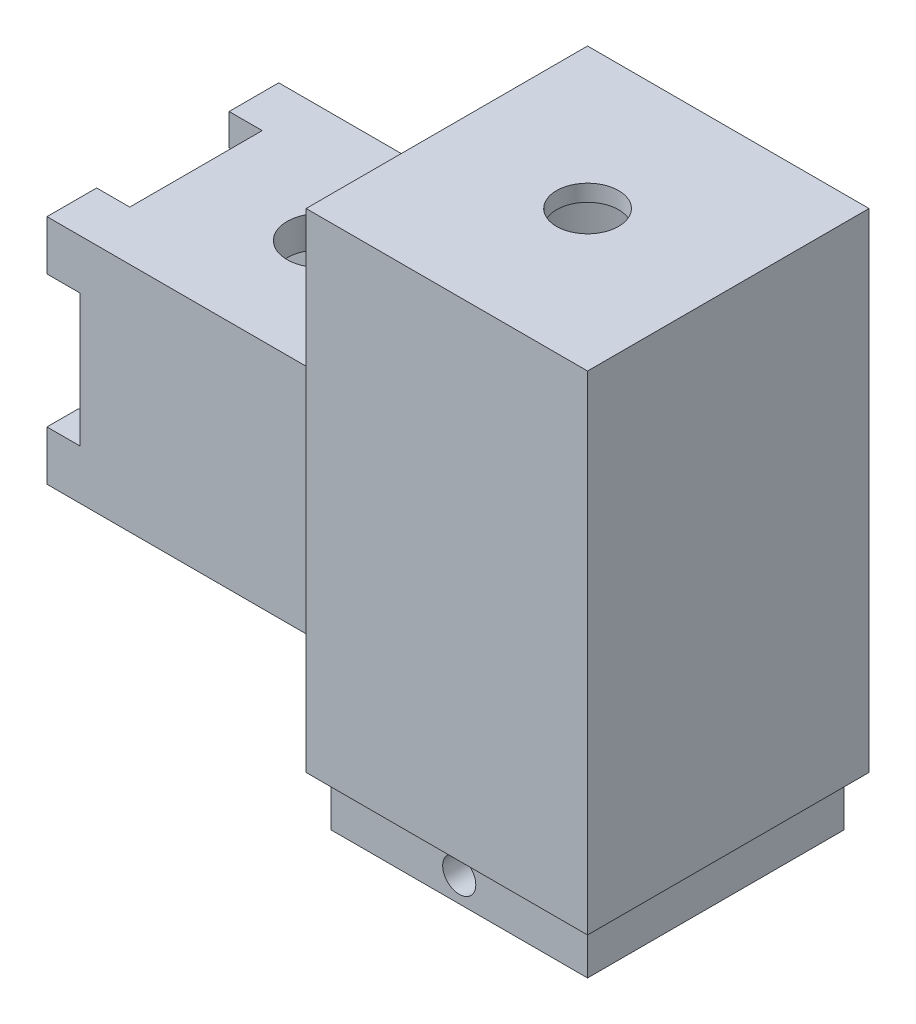
from build123d import *

# Parameters (mm, degrees)
CROQUIS1_W              = 28
CROQUIS1_H              = 28
CROQUIS1_W_2            = 20.4
CROQUIS1_H_2            = 20.4
SALIENTE_EXTRUIR1_DEPTH = 30.3
CROQUIS2_W              = 34
CROQUIS2_H              = 34
SALIENTE_EXTRUIR2_DEPTH = 31.5
CROQUIS3_R              = 12.625
CORTAR_EXTRUIR1_DEPTH   = 63
CROQUIS4_W              = 34
CROQUIS4_H              = 34
SALIENTE_EXTRUIR3_DEPTH = 2
CORTAR_EXTRUIR2_REACH   = 67
CROQUIS5_R              = 3.75
CORTAR_EXTRUIR3_REACH   = 36
CROQUIS6_W              = 15
CROQUIS6_H              = 11
CROQUIS7_W              = 34
CROQUIS7_H              = 34
CROQUIS7_W_2            = 31
CROQUIS7_H_2            = 31
CORTAR_EXTRUIR4_DEPTH   = 6
CROQUIS8_R              = 2
CORTAR_EXTRUIR7_DEPTH   = 40
CROQUIS10_R             = 4
CORTAR_EXTRUIR8_DEPTH   = 25.5
SALIENTE_EXTRUIR4_DEPTH = 4


with BuildPart() as part:
    # Croquis1 → Saliente-Extruir1 (new body)
    with BuildSketch(Plane(origin=(0, 0, 0), x_dir=(0, 0, -1), z_dir=(1, 0, 0))):
        Rectangle(CROQUIS1_W, CROQUIS1_H)
        Rectangle(CROQUIS1_W_2, CROQUIS1_H_2, mode=Mode.SUBTRACT)
    extrude(amount=SALIENTE_EXTRUIR1_DEPTH)

    # Croquis2 → Saliente-Extruir2 (add, symmetric)
    with BuildSketch(Plane(origin=(0, 0, 0), x_dir=(1, 0, 0), z_dir=(0, 1, 0))):
        with Locations((47.3, 0)):
            Rectangle(CROQUIS2_W, CROQUIS2_H)
    extrude(amount=SALIENTE_EXTRUIR2_DEPTH, both=True)

    # Croquis3 → Cortar-Extruir1 (cut)
    with BuildSketch(Plane.XZ.offset(31.5)):
        with Locations((47.3, 0)):
            Circle(CROQUIS3_R)
    extrude(amount=-CORTAR_EXTRUIR1_DEPTH, mode=Mode.SUBTRACT)

    # Croquis4 → Saliente-Extruir3 (add)
    with BuildSketch(Plane(origin=(0, 31.5, 0), x_dir=(1, 0, 0), z_dir=(0, 1, 0))):
        with Locations((47.3, 0)):
            Rectangle(CROQUIS4_W, CROQUIS4_H)
    extrude(amount=SALIENTE_EXTRUIR3_DEPTH)

    # Croquis5 → Cortar-Extruir2 (cut, up to next)
    with BuildSketch(Plane(origin=(0, 33.5, 0), x_dir=(1, 0, 0), z_dir=(0, 1, 0)), mode=Mode.PRIVATE) as cortar_extruir2_sk1:
        with Locations((47.3, 0)):
            Circle(CROQUIS5_R)
    cortar_extruir2_tool1 = extrude(cortar_extruir2_sk1.sketch, amount=-CORTAR_EXTRUIR2_REACH, mode=Mode.PRIVATE) & part.part
    add(cortar_extruir2_tool1.solids().sort_by_distance((47.3, 33.5, 0))[0], mode=Mode.SUBTRACT)

    # Croquis6 → Cortar-Extruir3 (cut, up to next)
    with BuildSketch(Plane.ZY.offset(-30.3), mode=Mode.PRIVATE) as cortar_extruir3_sk1:
        with Locations((0, -26)):
            Rectangle(CROQUIS6_W, CROQUIS6_H)
    cortar_extruir3_tool1 = extrude(cortar_extruir3_sk1.sketch, amount=-CORTAR_EXTRUIR3_REACH, mode=Mode.PRIVATE) & part.part
    add(cortar_extruir3_tool1.solids().sort_by_distance((30.3, -26, 0))[0], mode=Mode.SUBTRACT)

    # Croquis7 → Cortar-Extruir4 (cut)
    with BuildSketch(Plane.XZ.offset(31.5)):
        with Locations((47.3, 0)):
            Rectangle(CROQUIS7_W, CROQUIS7_H)
        with Locations((47.3, 0)):
            Rectangle(CROQUIS7_W_2, CROQUIS7_H_2, mode=Mode.SUBTRACT)
    extrude(amount=-CORTAR_EXTRUIR4_DEPTH, mode=Mode.SUBTRACT)

    # Croquis8 → Cortar-Extruir7 (cut)
    with BuildSketch(Plane.XY.offset(15.5)):
        with Locations((47.3, -28.5)):
            Circle(CROQUIS8_R)
    extrude(amount=-CORTAR_EXTRUIR7_DEPTH, mode=Mode.SUBTRACT)

    # Croquis10 → Cortar-Extruir8 (cut)
    with BuildSketch(Plane(origin=(0, 14, 0), x_dir=(1, 0, 0), z_dir=(0, 1, 0))):
        with Locations((15, 0)):
            Circle(CROQUIS10_R)
    extrude(amount=-CORTAR_EXTRUIR8_DEPTH, mode=Mode.SUBTRACT)

    # Croquis12 → Saliente-Extruir4 (add)
    with BuildSketch(Plane.ZY):
        Polygon((-8, 10.2), (-8, 14), (-14, 14), (-14, 8), (-10.2, 8), (-10.2, 10.2), align=None)
        Polygon((14, 10.2), (14, 14), (8, 14), (8, 10.2), (10.2, 10.2), (10.2, 8), (14, 8), align=None)
        Polygon((14, -14), (14, -8), (10.2, -8), (10.2, -10.2), (8, -10.2), (8, -14), align=None)
        Polygon((-10.2, -8), (-14, -8), (-14, -14), (-8, -14), (-8, -10.2), (-10.2, -10.2), align=None)
    extrude(amount=SALIENTE_EXTRUIR4_DEPTH)


solid = part.part
